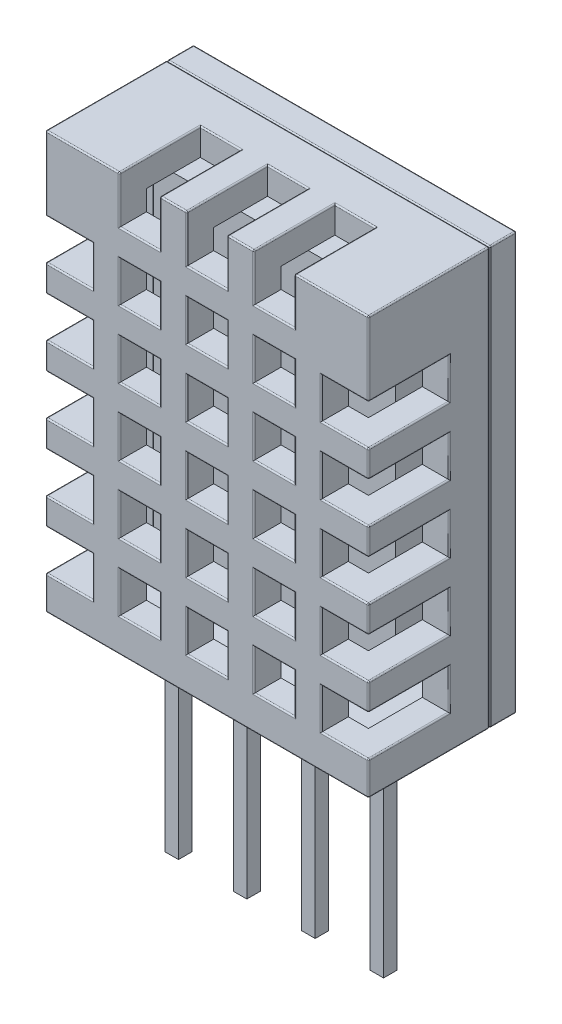
from build123d import *

# Parameters (mm, degrees)
SKETCH1_W           = 12
SKETCH1_H           = 15.5
BOSS_EXTRUDE1_DEPTH = 5.5
SKETCH2_W           = 0.5
SKETCH2_H           = 0.5
BOSS_EXTRUDE2_DEPTH = 8
SHELL2_T            = -1
SKETCH3_W           = 1.5
SKETCH3_H           = 1.75
CUT_EXTRUDE1_DEPTH  = 3
SKETCH4_W           = 1.5
SKETCH4_H           = 1.5
CUT_EXTRUDE2_DEPTH  = 3
SKETCH5_W           = 1.75
SKETCH5_H           = 1.5
CUT_EXTRUDE3_DEPTH  = 3
SKETCH6_W           = 12
SKETCH6_H           = 15.5
SKETCH6_W_2         = 10
SKETCH6_H_2         = 13.5
CUT_EXTRUDE4_DEPTH  = 1
SKETCH8_W           = 12
SKETCH8_H           = 15.5
BOSS_EXTRUDE3_DEPTH = 0.99
SKETCH9_W           = 0.7
SKETCH9_H           = 0.7
SKETCH9_W_2         = 0.5
SKETCH9_H_2         = 0.5
CUT_EXTRUDE5_DEPTH  = 1
FILLET1_R           = 0.05
FILLET2_R           = 0.05
SKETCH10_W          = 9
SKETCH10_H          = 12.5
BOSS_EXTRUDE4_DEPTH = 2


with BuildPart() as part:
    # Sketch1 → Boss-Extrude1 (new body)
    with BuildSketch(Plane.XY):
        with Locations((6, 7.75)):
            Rectangle(SKETCH1_W, SKETCH1_H)
    extrude(amount=BOSS_EXTRUDE1_DEPTH)

    # Sketch2 → Boss-Extrude2 (add)
    with BuildSketch(Plane.XZ):
        with Locations((2.19, 2.75)):
            Rectangle(SKETCH2_W, SKETCH2_H)
        with Locations((4.73, 2.75)):
            Rectangle(SKETCH2_W, SKETCH2_H)
        with Locations((7.27, 2.75)):
            Rectangle(SKETCH2_W, SKETCH2_H)
        with Locations((9.81, 2.75)):
            Rectangle(SKETCH2_W, SKETCH2_H)
    extrude(amount=BOSS_EXTRUDE2_DEPTH)

    # Shell2
    shell2_openings = [part.faces().sort_by_distance(p)[0] for p in [
        (6, 7.75, 0),
    ]]
    offset(amount=SHELL2_T, openings=shell2_openings, kind=Kind.INTERSECTION)

    # Sketch3 → Cut-Extrude1 (cut)
    with BuildSketch(Plane.XY.offset(5.5)):
        with Locations((3.5, 14.625)):
            Rectangle(SKETCH3_W, SKETCH3_H)
        with Locations((6, 14.625)):
            Rectangle(SKETCH3_W, SKETCH3_H)
        with Locations((8.5, 14.625)):
            Rectangle(SKETCH3_W, SKETCH3_H)
    extrude(amount=-CUT_EXTRUDE1_DEPTH, mode=Mode.SUBTRACT)

    # Sketch4 → Cut-Extrude2 (cut)
    with BuildSketch(Plane.XY.offset(5.5)):
        with Locations((3.5, 12)):
            Rectangle(SKETCH4_W, SKETCH4_H)
        with Locations((6, 12)):
            Rectangle(SKETCH4_W, SKETCH4_H)
        with Locations((8.5, 12)):
            Rectangle(SKETCH4_W, SKETCH4_H)
        with Locations((6, 9.5)):
            Rectangle(SKETCH4_W, SKETCH4_H)
        with Locations((8.5, 9.5)):
            Rectangle(SKETCH4_W, SKETCH4_H)
        with Locations((6, 7)):
            Rectangle(SKETCH4_W, SKETCH4_H)
        with Locations((8.5, 7)):
            Rectangle(SKETCH4_W, SKETCH4_H)
        with Locations((6, 4.5)):
            Rectangle(SKETCH4_W, SKETCH4_H)
        with Locations((8.5, 4.5)):
            Rectangle(SKETCH4_W, SKETCH4_H)
        with Locations((6, 2)):
            Rectangle(SKETCH4_W, SKETCH4_H)
        with Locations((8.5, 2)):
            Rectangle(SKETCH4_W, SKETCH4_H)
        with Locations((3.5, 9.5)):
            Rectangle(SKETCH4_W, SKETCH4_H)
        with Locations((3.5, 7)):
            Rectangle(SKETCH4_W, SKETCH4_H)
        with Locations((3.5, 4.5)):
            Rectangle(SKETCH4_W, SKETCH4_H)
        with Locations((3.5, 2)):
            Rectangle(SKETCH4_W, SKETCH4_H)
    extrude(amount=-CUT_EXTRUDE2_DEPTH, mode=Mode.SUBTRACT)

    # Sketch5 → Cut-Extrude3 (cut)
    with BuildSketch(Plane.XY.offset(5.5)):
        with Locations((0.875, 12)):
            Rectangle(SKETCH5_W, SKETCH5_H)
        with Locations((11.125, 12)):
            Rectangle(SKETCH5_W, SKETCH5_H)
        with Locations((11.125, 9.5)):
            Rectangle(SKETCH5_W, SKETCH5_H)
        with Locations((11.125, 7)):
            Rectangle(SKETCH5_W, SKETCH5_H)
        with Locations((11.125, 4.5)):
            Rectangle(SKETCH5_W, SKETCH5_H)
        with Locations((11.125, 2)):
            Rectangle(SKETCH5_W, SKETCH5_H)
        with Locations((0.875, 9.5)):
            Rectangle(SKETCH5_W, SKETCH5_H)
        with Locations((0.875, 7)):
            Rectangle(SKETCH5_W, SKETCH5_H)
        with Locations((0.875, 4.5)):
            Rectangle(SKETCH5_W, SKETCH5_H)
        with Locations((0.875, 2)):
            Rectangle(SKETCH5_W, SKETCH5_H)
    extrude(amount=-CUT_EXTRUDE3_DEPTH, mode=Mode.SUBTRACT)

    # Sketch6 → Cut-Extrude4 (cut)
    with BuildSketch(Plane(origin=(0, 0, 0), x_dir=(-1, 0, 0), z_dir=(0, 0, -1))):
        with Locations((-6, 7.75)):
            Rectangle(SKETCH6_W, SKETCH6_H)
        with Locations((-6, 7.75)):
            Rectangle(SKETCH6_W_2, SKETCH6_H_2, mode=Mode.SUBTRACT)
    extrude(amount=-CUT_EXTRUDE4_DEPTH, mode=Mode.SUBTRACT)

    # Sketch9 → Cut-Extrude5 (cut)
    with BuildSketch(Plane.XZ):
        with Locations((2.19, 2.75)):
            Rectangle(SKETCH9_W, SKETCH9_H)
        with Locations((2.19, 2.75)):
            Rectangle(SKETCH9_W_2, SKETCH9_H_2, mode=Mode.SUBTRACT)
        with Locations((4.73, 2.75)):
            Rectangle(SKETCH9_W, SKETCH9_H)
        with Locations((4.73, 2.75)):
            Rectangle(SKETCH9_W_2, SKETCH9_H_2, mode=Mode.SUBTRACT)
        with Locations((7.27, 2.75)):
            Rectangle(SKETCH9_W, SKETCH9_H)
        with Locations((7.27, 2.75)):
            Rectangle(SKETCH9_W_2, SKETCH9_H_2, mode=Mode.SUBTRACT)
        with Locations((9.81, 2.75)):
            Rectangle(SKETCH9_W, SKETCH9_H)
        with Locations((9.81, 2.75)):
            Rectangle(SKETCH9_W_2, SKETCH9_H_2, mode=Mode.SUBTRACT)
    extrude(amount=-CUT_EXTRUDE5_DEPTH, mode=Mode.SUBTRACT)

    # Fillet1
    fillet1_edges = [part.edges().sort_by_distance(p)[0] for p in [
        (0, 2.75, 4),
        (0, 5.25, 4),
        (0, 3.25, 5.5),
        (0, 0.625, 5.5),
        (6, 0, 5.5),
        (12, 0.625, 5.5),
        (12, 3.25, 5.5),
        (12, 5.75, 5.5),
        (12, 8.25, 5.5),
        (12, 10.75, 5.5),
        (0, 7.75, 4),
        (12, 14.125, 5.5),
        (10.625, 15.5, 5.5),
        (7.25, 15.5, 5.5),
        (4.75, 15.5, 5.5),
        (1.375, 15.5, 5.5),
        (0, 14.125, 5.5),
        (0, 10.75, 5.5),
        (0, 8.25, 5.5),
        (0, 5.75, 5.5),
        (0, 10.25, 4),
        (2.75, 15.5, 4),
        (2.75, 14.625, 5.5),
        (4.25, 14.625, 5.5),
        (3.5, 13.75, 5.5),
        (0, 12.75, 4),
        (3.5, 15.5, 2.5),
        (5.25, 15.5, 4),
        (5.25, 14.625, 5.5),
        (0, 15.5, 3.25),
        (6.75, 14.625, 5.5),
        (6, 13.75, 5.5),
        (6, 15.5, 2.5),
        (7.75, 15.5, 4),
        (7.75, 14.625, 5.5),
        (12, 11.25, 4),
        (9.25, 14.625, 5.5),
        (8.5, 13.75, 5.5),
        (8.5, 15.5, 2.5),
        (12, 8.75, 4),
        (2.75, 12, 5.5),
        (3.5, 12.75, 5.5),
        (4.25, 12, 5.5),
        (12, 6.25, 4),
        (3.5, 11.25, 5.5),
        (5.25, 12, 5.5),
        (6, 12.75, 5.5),
        (12, 3.75, 4),
        (6.75, 12, 5.5),
        (6, 11.25, 5.5),
        (7.75, 12, 5.5),
        (12, 1.25, 4),
        (8.5, 12.75, 5.5),
        (9.25, 12, 5.5),
        (8.5, 11.25, 5.5),
        (5.25, 9.5, 5.5),
        (12, 0, 3.25),
        (6, 10.25, 5.5),
        (6.75, 9.5, 5.5),
        (6, 8.75, 5.5),
        (4.25, 15.5, 4),
        (7.75, 9.5, 5.5),
        (8.5, 10.25, 5.5),
        (9.25, 9.5, 5.5),
        (6.75, 15.5, 4),
        (8.5, 8.75, 5.5),
        (5.25, 7, 5.5),
        (6, 7.75, 5.5),
        (6.75, 7, 5.5),
        (9.25, 15.5, 4),
        (6, 6.25, 5.5),
        (7.75, 7, 5.5),
        (8.5, 7.75, 5.5),
        (12, 15.5, 3.25),
        (9.25, 7, 5.5),
        (8.5, 6.25, 5.5),
        (5.25, 4.5, 5.5),
        (6, 5.25, 5.5),
        (6.75, 4.5, 5.5),
        (6, 3.75, 5.5),
        (7.75, 4.5, 5.5),
        (8.5, 5.25, 5.5),
        (9.25, 4.5, 5.5),
        (8.5, 3.75, 5.5),
        (5.25, 2, 5.5),
        (6, 2.75, 5.5),
        (6.75, 2, 5.5),
        (6, 1.25, 5.5),
        (7.75, 2, 5.5),
        (8.5, 2.75, 5.5),
        (9.25, 2, 5.5),
        (8.5, 1.25, 5.5),
        (2.75, 9.5, 5.5),
        (3.5, 10.25, 5.5),
        (4.25, 9.5, 5.5),
        (3.5, 8.75, 5.5),
        (2.75, 7, 5.5),
        (3.5, 7.75, 5.5),
        (4.25, 7, 5.5),
        (3.5, 6.25, 5.5),
        (2.75, 4.5, 5.5),
        (3.5, 5.25, 5.5),
        (4.25, 4.5, 5.5),
        (3.5, 3.75, 5.5),
        (2.75, 2, 5.5),
        (3.5, 2.75, 5.5),
        (4.25, 2, 5.5),
        (3.5, 1.25, 5.5),
        (0.875, 12.75, 5.5),
        (1.75, 12, 5.5),
        (0, 11.25, 4),
        (0.875, 11.25, 5.5),
        (0, 12, 2.5),
        (10.25, 12, 5.5),
        (12, 12.75, 4),
        (11.125, 12.75, 5.5),
        (11.125, 11.25, 5.5),
        (12, 12, 2.5),
        (10.25, 9.5, 5.5),
        (12, 10.25, 4),
        (11.125, 10.25, 5.5),
        (11.125, 8.75, 5.5),
        (12, 9.5, 2.5),
        (10.25, 7, 5.5),
        (12, 7.75, 4),
        (11.125, 7.75, 5.5),
        (11.125, 6.25, 5.5),
        (12, 7, 2.5),
        (10.25, 4.5, 5.5),
        (12, 5.25, 4),
        (11.125, 5.25, 5.5),
        (11.125, 3.75, 5.5),
        (12, 4.5, 2.5),
        (10.25, 2, 5.5),
        (12, 2.75, 4),
        (11.125, 2.75, 5.5),
        (11.125, 1.25, 5.5),
        (12, 2, 2.5),
        (0.875, 10.25, 5.5),
        (1.75, 9.5, 5.5),
        (0, 8.75, 4),
        (0.875, 8.75, 5.5),
        (0, 9.5, 2.5),
        (0.875, 7.75, 5.5),
        (1.75, 7, 5.5),
        (0, 6.25, 4),
        (0.875, 6.25, 5.5),
        (0, 7, 2.5),
        (0.875, 5.25, 5.5),
        (1.75, 4.5, 5.5),
        (0, 3.75, 4),
        (0.875, 3.75, 5.5),
        (0, 4.5, 2.5),
        (0.875, 2.75, 5.5),
        (1.75, 2, 5.5),
        (0, 1.25, 4),
        (0.875, 1.25, 5.5),
        (0, 2, 2.5),
        (6, 0, 1),
        (0, 7.75, 1),
        (6, 15.5, 1),
        (12, 7.75, 1),
        (2.19, 0, 3.1),
        (2.54, 0, 2.75),
        (2.19, 0, 2.4),
        (1.84, 0, 2.75),
        (4.73, 0, 3.1),
        (5.08, 0, 2.75),
        (4.73, 0, 2.4),
        (4.38, 0, 2.75),
        (7.27, 0, 3.1),
        (7.62, 0, 2.75),
        (7.27, 0, 2.4),
        (6.92, 0, 2.75),
        (9.81, 0, 3.1),
        (10.16, 0, 2.75),
        (9.81, 0, 2.4),
        (9.46, 0, 2.75),
        (0, 0, 3.25),
    ]]
    fillet(fillet1_edges, radius=FILLET1_R)


with BuildPart() as body_2:
    # Sketch8 → Boss-Extrude3 (new body)
    with BuildSketch(Plane.XY.offset(0.99)):
        with Locations((6, 7.75)):
            Rectangle(SKETCH8_W, SKETCH8_H)
    extrude(amount=-BOSS_EXTRUDE3_DEPTH)

    # Fillet2
    fillet2_edges = [body_2.edges().sort_by_distance(p)[0] for p in [
        (0, 7.75, 0),
        (6, 0, 0),
        (12, 7.75, 0),
        (6, 0, 0.99),
        (0, 7.75, 0.99),
        (6, 15.5, 0.99),
        (12, 7.75, 0.99),
        (6, 15.5, 0),
        (12, 0, 0.495),
        (0, 0, 0.495),
        (0, 15.5, 0.495),
        (12, 15.5, 0.495),
    ]]
    fillet(fillet2_edges, radius=FILLET2_R)

    # Sketch10 → Boss-Extrude4 (add)
    with BuildSketch(Plane.XY.offset(0.99)):
        with Locations((6, 7.75)):
            Rectangle(SKETCH10_W, SKETCH10_H)
    extrude(amount=BOSS_EXTRUDE4_DEPTH)


solid = Compound([part.part, body_2.part])
